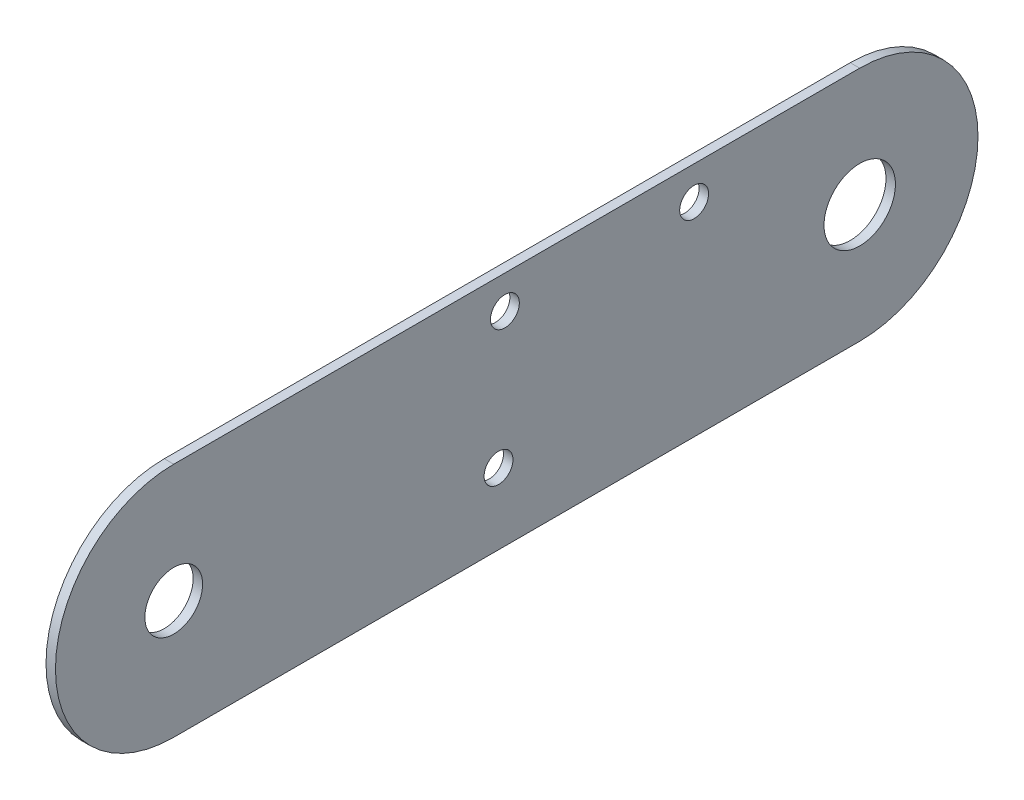
from build123d import *

# Parameters (mm, degrees)
SKETCH_1_R      = 7.55
SKETCH_1_R_2    = 6.1
SKETCH_1_R_3    = 3.05
EXTRUDE_1_DEPTH = 2


with BuildPart() as part:
    # 草图1 → 凸台-拉伸1 (new body)
    with BuildSketch(Plane(origin=(0, 0, 0), x_dir=(0, 0, -1), z_dir=(1, 0, 0))):
        with BuildLine():
            Line((19.426316451, -58.647367097), (-125.573683549, -58.647367097))
            ThreePointArc((-125.573683549, -58.647367097), (-150.573683549, -33.647367097), (-125.573683549, -8.647367097))
            Line((-125.573683549, -8.647367097), (4.992559722, -8.647367097))
            Line((4.992559722, -8.647367097), (19.426316451, -8.647367097))
            ThreePointArc((19.426316451, -8.647367097), (44.426316451, -33.647367097), (19.426316451, -58.647367097))
        make_face()
        with Locations((19.426316451, -33.647367097)):
            Circle(SKETCH_1_R, mode=Mode.SUBTRACT)
        with Locations((-125.573683549, -33.647367097)):
            Circle(SKETCH_1_R_2, mode=Mode.SUBTRACT)
        with Locations((-56.921571535, -43.647367097)):
            Circle(SKETCH_1_R_3, mode=Mode.SUBTRACT)
        with Locations((-15.573683549, -15.647367097)):
            Circle(SKETCH_1_R_3, mode=Mode.SUBTRACT)
        with Locations((-55.573683549, -15.647367097)):
            Circle(SKETCH_1_R_3, mode=Mode.SUBTRACT)
    extrude(amount=EXTRUDE_1_DEPTH)


solid = part.part
